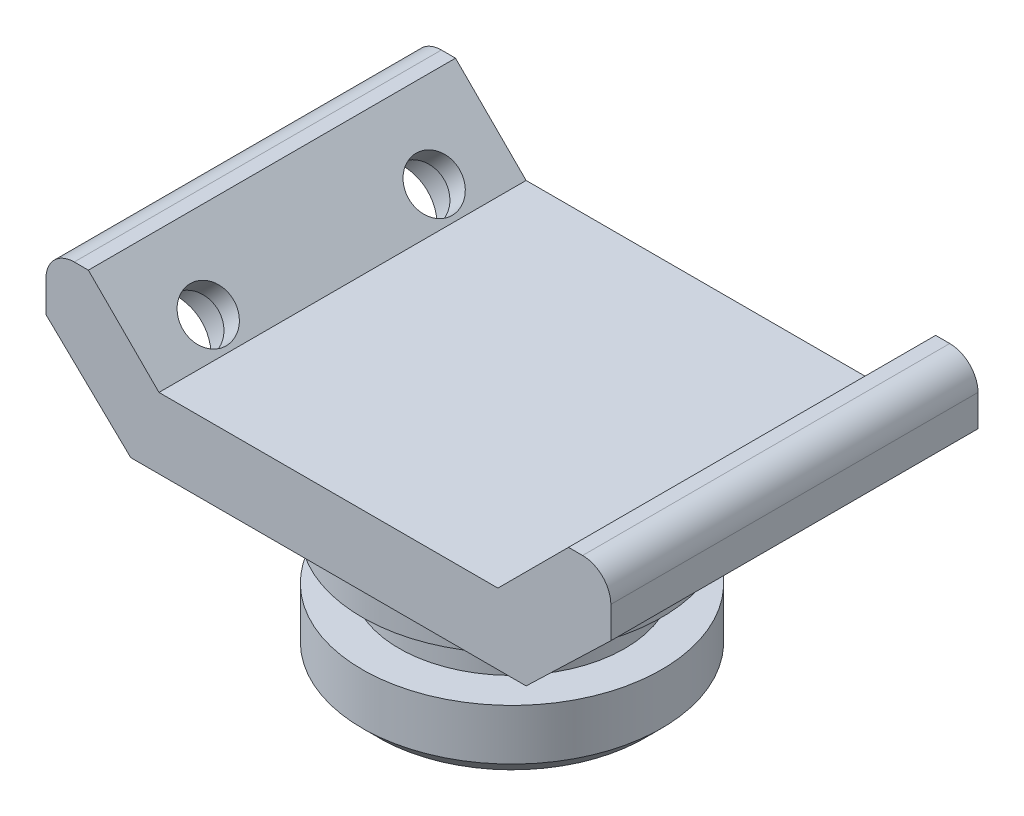
from build123d import *

# Parameters (mm, degrees)
BOSS_EXTRUDE1_DEPTH                                 = 32.5
CBORE_FOR_M8_HEX_SOCKET_HEAD_CAP_SCREW1_D           = 9
CBORE_FOR_M8_HEX_SOCKET_HEAD_CAP_SCREW1_CBORE_D     = 15
CBORE_FOR_M8_HEX_SOCKET_HEAD_CAP_SCREW1_CBORE_DEPTH = 8.6
FILLET1_R                                           = 5


with BuildPart() as part:
    # Sketch1 → Boss-Extrude1 (new body, symmetric)
    with BuildSketch(Plane.XY):
        Polygon((-35, 0), (35, 0), (50, 14.424703588), (50, 25), (42.5, 25), (30, 12.5), (-30, 12.5), (-42.5, 25), (-50, 25), (-50, 14.424703588), align=None)
    extrude(amount=BOSS_EXTRUDE1_DEPTH, both=True)

    # Sketch2 → Revolve1 (revolve)
    with BuildSketch(Plane.XY):
        Polygon((23.5, -30), (26.5, -27), (26.5, -18), (20, -18), (20, -10), (26.5, -10), (26.5, 0), (0, 0), (0, -30), align=None)
    revolve(axis=Axis((0, 0, 0), (0, -1, 0)))

    # CBORE for M8 Hex Socket Head Cap Screw1 (through all)
    with Locations(Plane(origin=(16.815959791, -17.486626004, 0), x_dir=(-0.720794011, -0.69314933, 0), z_dir=(0.69314933, -0.720794011, 0))):
        with Locations((-35.632982274, -20), (-35.632982274, 20)):
            cbore_for_m8_hex_socket_head_cap_screw1 = CounterBoreHole(CBORE_FOR_M8_HEX_SOCKET_HEAD_CAP_SCREW1_D / 2, CBORE_FOR_M8_HEX_SOCKET_HEAD_CAP_SCREW1_CBORE_D / 2, CBORE_FOR_M8_HEX_SOCKET_HEAD_CAP_SCREW1_CBORE_DEPTH)

    # Mirror1: CBORE for M8 Hex Socket Head Cap Screw1 across plane
    add(cbore_for_m8_hex_socket_head_cap_screw1.mirror(Plane(origin=(0, 0, 0), x_dir=(0, 0, 1), z_dir=(1, 0, 0))), mode=Mode.SUBTRACT)

    # Fillet1
    fillet1_edges = [part.edges().sort_by_distance(p)[0] for p in [
        (50, 25, 0),
        (-50, 25, 0),
    ]]
    fillet(fillet1_edges, radius=FILLET1_R)


solid = part.part
